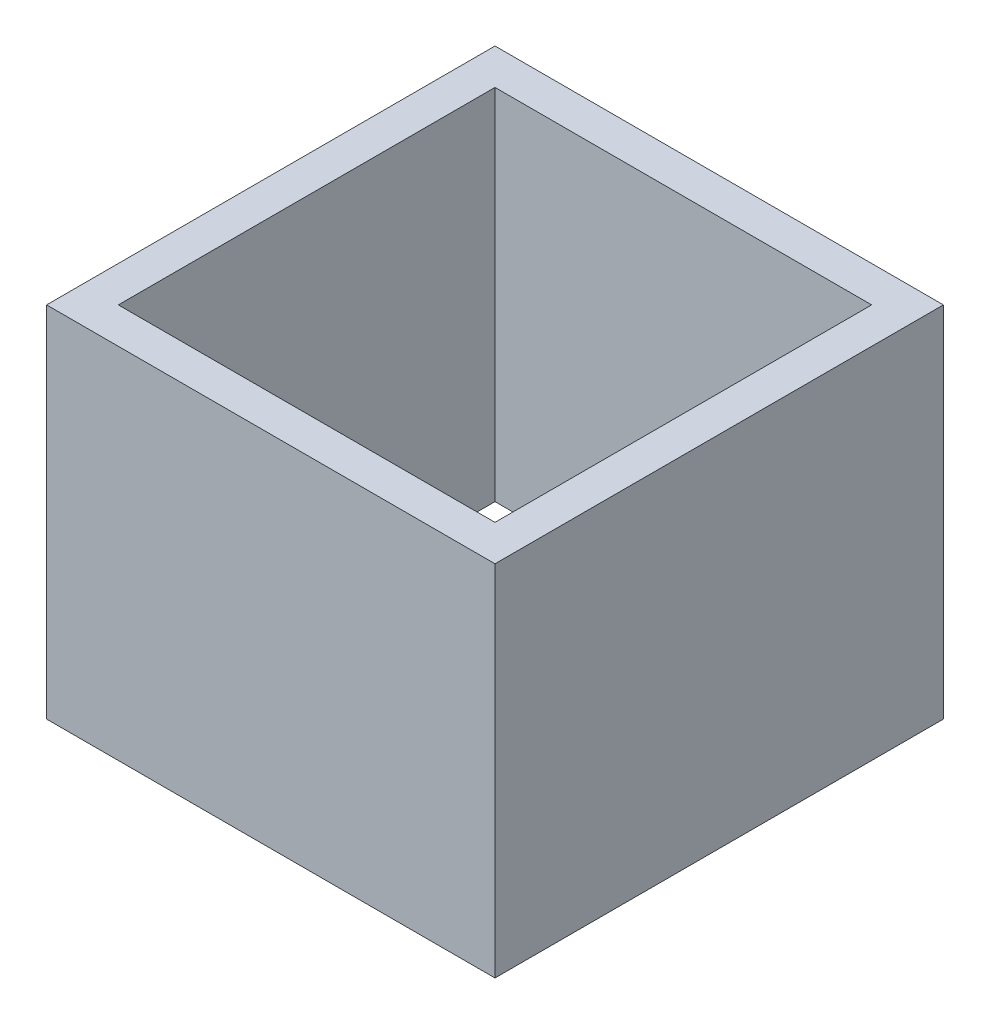
from build123d import *

# Parameters (mm, degrees)
SKETCH_1_W      = 25
SKETCH_1_H      = 25
SKETCH_1_W_2    = 21
SKETCH_1_H_2    = 21
EXTRUDE_1_DEPTH = 20


with BuildPart() as part:
    # Эскиз1 → Вытянуть-Тонкостенный1 (new body)
    with BuildSketch(Plane(origin=(0, 0, 0), x_dir=(1, 0, 0), z_dir=(0, 1, 0))):
        Rectangle(SKETCH_1_W, SKETCH_1_H)
        Rectangle(SKETCH_1_W_2, SKETCH_1_H_2, mode=Mode.SUBTRACT)
    extrude(amount=EXTRUDE_1_DEPTH)


solid = part.part
